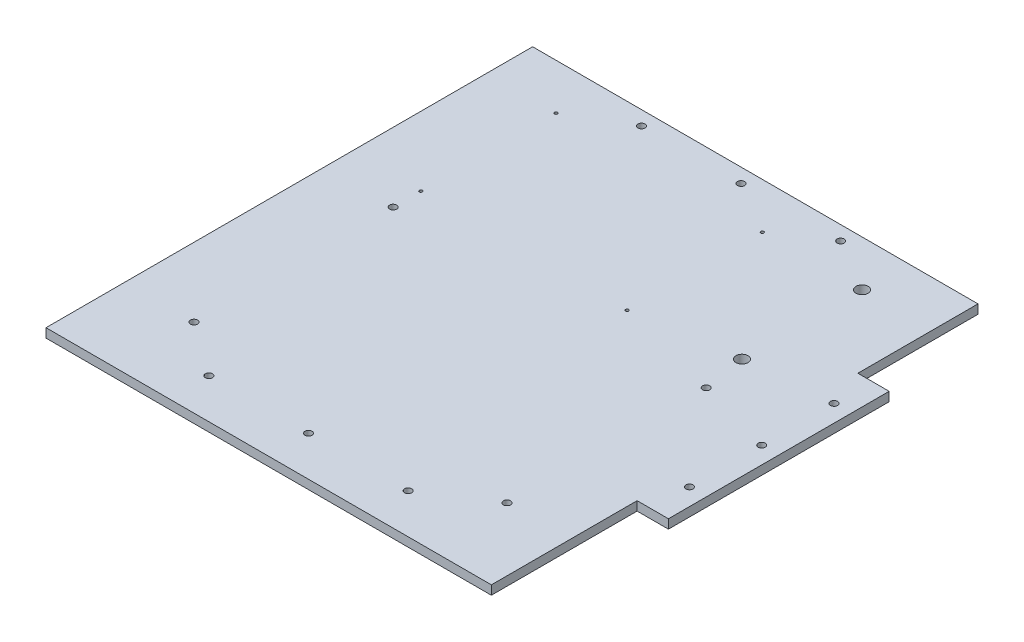
from build123d import *

# Parameters (mm, degrees)
SKETCH1_W           = 313
SKETCH1_H           = 342
BOSS_EXTRUDE1_DEPTH = 6.35
SKETCH3_W           = 22
SKETCH3_H           = 155.14040353
SKETCH3_R           = 2.5
BOSS_EXTRUDE2_DEPTH = 6.35
SKETCH2_R           = 2.5
CUT_EXTRUDE1_DEPTH  = 7.35
SKETCH4_R           = 4.25
SKETCH4_R_2         = 2.5
SKETCH4_R_3         = 1.05
CUT_EXTRUDE2_DEPTH  = 7.35


with BuildPart() as part:
    # Sketch1 → Boss-Extrude1 (new body)
    with BuildSketch(Plane(origin=(0, 0, 0), x_dir=(1, 0, 0), z_dir=(0, 1, 0))):
        Rectangle(SKETCH1_W, SKETCH1_H)
    extrude(amount=-BOSS_EXTRUDE1_DEPTH)

    # Sketch3 → Boss-Extrude2 (add)
    with BuildSketch(Plane(origin=(0, 0, 0), x_dir=(1, 0, 0), z_dir=(0, 1, 0))):
        with Locations((167.5, 9)):
            Rectangle(SKETCH3_W, SKETCH3_H)
        with Locations((166.5, 9)):
            Circle(SKETCH3_R, mode=Mode.SUBTRACT)
        with Locations((166.5, -41.8)):
            Circle(SKETCH3_R, mode=Mode.SUBTRACT)
        with Locations((166.5, 59.8)):
            Circle(SKETCH3_R, mode=Mode.SUBTRACT)
    extrude(amount=-BOSS_EXTRUDE2_DEPTH)

    # Sketch2 → Cut-Extrude1 (cut, through all)
    with BuildSketch(Plane(origin=(0, 0, 0), x_dir=(1, 0, 0), z_dir=(0, 1, 0))):
        with Locations((0, -143)):
            Circle(SKETCH2_R)
        with Locations((-70, -143)):
            Circle(SKETCH2_R)
        with Locations((70, -143)):
            Circle(SKETCH2_R)
        with Locations((-70, 161)):
            Circle(SKETCH2_R)
        with Locations((0, 161)):
            Circle(SKETCH2_R)
        with Locations((70, 161)):
            Circle(SKETCH2_R)
    extrude(amount=-CUT_EXTRUDE1_DEPTH, mode=Mode.SUBTRACT)

    # Sketch4 → Cut-Extrude2 (cut, through all)
    with BuildSketch(Plane(origin=(0, 0, 0), x_dir=(1, 0, 0), z_dir=(0, 1, 0))):
        with Locations((107.204882136, 138.829587854)):
            Circle(SKETCH4_R)
        with Locations((107.204882136, 54.425387854)):
            Circle(SKETCH4_R)
        with Locations((-107.911484214, -115.605535397)):
            Circle(SKETCH4_R_2)
        with Locations((-107.911484214, 24.394464603)):
            Circle(SKETCH4_R_2)
        with Locations((112.088515786, 24.394464603)):
            Circle(SKETCH4_R_2)
        with Locations((112.088515786, -115.605535397)):
            Circle(SKETCH4_R_2)
        with Locations((-107.911484214, 138.829587854)):
            Circle(SKETCH4_R_3)
        with Locations((37.088515786, 138.829587854)):
            Circle(SKETCH4_R_3)
        with Locations((37.088515786, 43.829587854)):
            Circle(SKETCH4_R_3)
        with Locations((-107.911484214, 43.829587854)):
            Circle(SKETCH4_R_3)
    extrude(amount=-CUT_EXTRUDE2_DEPTH, mode=Mode.SUBTRACT)


solid = part.part
